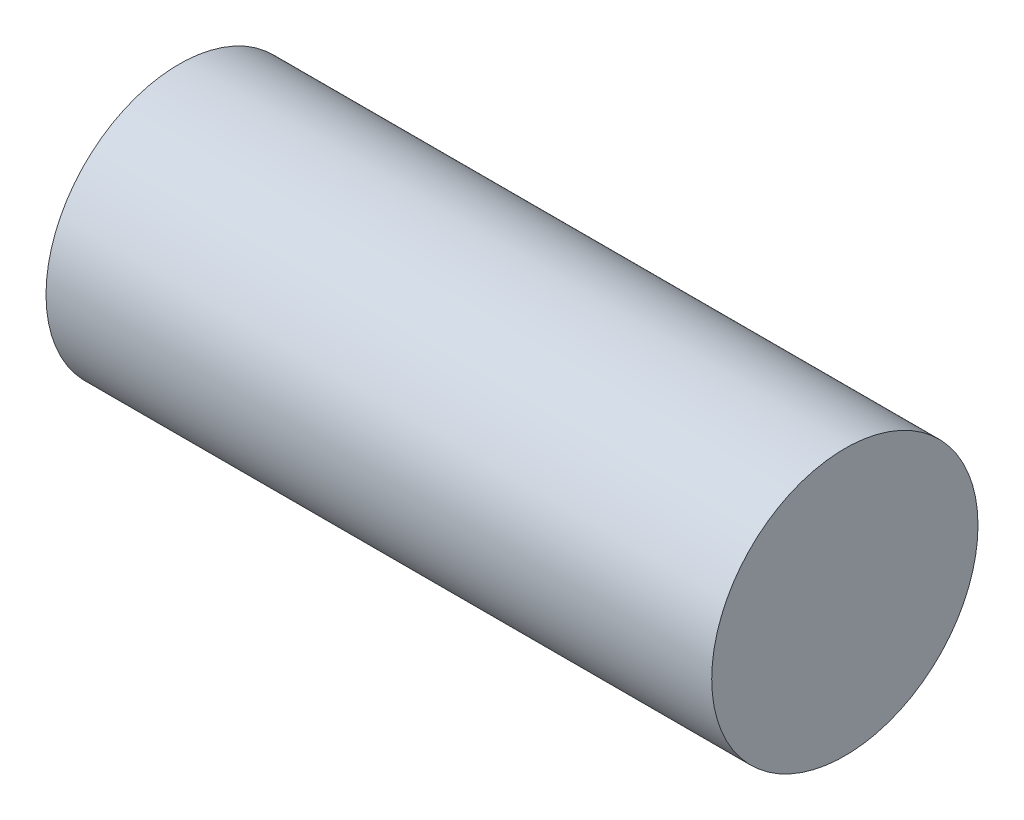
from build123d import *

# Parameters (mm, degrees)
SKETCH1_R           = 0.2
BOSS_EXTRUDE1_DEPTH = 1


with BuildPart() as part:
    # Sketch1 → Boss-Extrude1 (new body)
    with BuildSketch(Plane(origin=(0, 0, 0), x_dir=(0, 0, -1), z_dir=(1, 0, 0))):
        Circle(SKETCH1_R)
    extrude(amount=BOSS_EXTRUDE1_DEPTH)


solid = part.part
